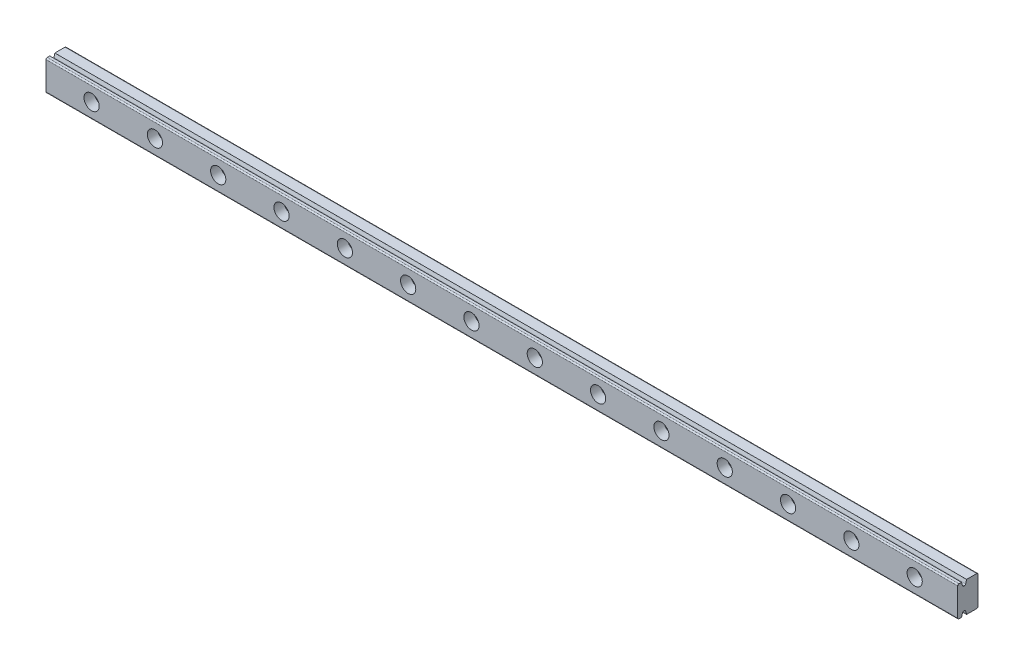
from build123d import *

# Parameters (mm, degrees)
BOSS_EXTRUDE1_DEPTH     = 450
SKETCH2_R               = 1.75
CUT_EXTRUDE1_DEPTH      = 10
SKETCH3_R               = 3
CUT_EXTRUDE2_DEPTH      = 4
CHAMFER1_SIZE           = 0.5
CHAMFER1_SIZE2          = 1.743707222
CHAMFER1_PART_2_SIZE    = 0.5
CHAMFER1_PART_2_SIZE2   = 1.743707222
FILLET1_R               = 0.5
SKETCH4_W               = 45
SKETCH4_H               = 180.260452365
SKETCH4_H_2             = 288.291106743
CUT_EXTRUDE3_DEPTH      = 1
CUT_EXTRUDE3_DEPTH_BACK = 9


with BuildPart() as part:
    # Sketch1 → Boss-Extrude1 (new body)
    with BuildSketch(Plane(origin=(0, 0, 0), x_dir=(0, 0, -1), z_dir=(1, 0, 0))):
        Polygon((-0.5, 6), (4, 6), (4, -6), (-0.5, -6), (-0.5, -4.25), (-2.5, -4.25), (-2.5, -6), (-4, -6), (-4, 6), (-2.5, 6), (-2.5, 4.25), (-0.5, 4.25), align=None)
    extrude(amount=BOSS_EXTRUDE1_DEPTH)

    # Sketch2 → Cut-Extrude1 (cut)
    with BuildSketch(Plane.XY.offset(4)):
        with Locations((13, 0)):
            Circle(SKETCH2_R)
        with Locations((38, 0)):
            Circle(SKETCH2_R)
        with Locations((63, 0)):
            Circle(SKETCH2_R)
        with Locations((88, 0)):
            Circle(SKETCH2_R)
        with Locations((113, 0)):
            Circle(SKETCH2_R)
        with Locations((138, 0)):
            Circle(SKETCH2_R)
        with Locations((163, 0)):
            Circle(SKETCH2_R)
        with Locations((188, 0)):
            Circle(SKETCH2_R)
        with Locations((213, 0)):
            Circle(SKETCH2_R)
        with Locations((238, 0)):
            Circle(SKETCH2_R)
        with Locations((263, 0)):
            Circle(SKETCH2_R)
        with Locations((288, 0)):
            Circle(SKETCH2_R)
        with Locations((313, 0)):
            Circle(SKETCH2_R)
        with Locations((338, 0)):
            Circle(SKETCH2_R)
        with Locations((363, 0)):
            Circle(SKETCH2_R)
        with Locations((388, 0)):
            Circle(SKETCH2_R)
        with Locations((413, 0)):
            Circle(SKETCH2_R)
        with Locations((438, 0)):
            Circle(SKETCH2_R)
    extrude(amount=-CUT_EXTRUDE1_DEPTH, mode=Mode.SUBTRACT)

    # Sketch3 → Cut-Extrude2 (cut)
    with BuildSketch(Plane.XY.offset(4)):
        with Locations((13, 0)):
            Circle(SKETCH3_R)
        with Locations((38, 0)):
            Circle(SKETCH3_R)
        with Locations((63, 0)):
            Circle(SKETCH3_R)
        with Locations((88, 0)):
            Circle(SKETCH3_R)
        with Locations((113, 0)):
            Circle(SKETCH3_R)
        with Locations((138, 0)):
            Circle(SKETCH3_R)
        with Locations((163, 0)):
            Circle(SKETCH3_R)
        with Locations((188, 0)):
            Circle(SKETCH3_R)
        with Locations((213, 0)):
            Circle(SKETCH3_R)
        with Locations((238, 0)):
            Circle(SKETCH3_R)
        with Locations((263, 0)):
            Circle(SKETCH3_R)
        with Locations((288, 0)):
            Circle(SKETCH3_R)
        with Locations((313, 0)):
            Circle(SKETCH3_R)
        with Locations((338, 0)):
            Circle(SKETCH3_R)
        with Locations((363, 0)):
            Circle(SKETCH3_R)
        with Locations((388, 0)):
            Circle(SKETCH3_R)
        with Locations((413, 0)):
            Circle(SKETCH3_R)
        with Locations((438, 0)):
            Circle(SKETCH3_R)
    extrude(amount=-CUT_EXTRUDE2_DEPTH, mode=Mode.SUBTRACT)

    # Chamfer1
    chamfer1_edges = [part.edges().sort_by_distance(p)[0] for p in [
        (225, -4.25, 0.5),
        (225, -4.25, 2.5),
    ]]
    chamfer1_side = [part.faces().sort_by_distance(p)[0] for p in [
        (225, -4.25, 1.5),
    ]]
    chamfer(chamfer1_edges, length=CHAMFER1_SIZE, length2=CHAMFER1_SIZE2, reference=chamfer1_side[0])

    # Chamfer1 part 2
    chamfer1_part_2_edges = [part.edges().sort_by_distance(p)[0] for p in [
        (225, 4.25, 2.5),
        (225, 4.25, 0.5),
    ]]
    chamfer1_part_2_side = [part.faces().sort_by_distance(p)[0] for p in [
        (225, 4.25, 1.5),
    ]]
    chamfer(chamfer1_part_2_edges, length=CHAMFER1_PART_2_SIZE, length2=CHAMFER1_PART_2_SIZE2, reference=chamfer1_part_2_side[0])

    # Fillet1
    fillet1_edges = [part.edges().sort_by_distance(p)[0] for p in [
        (450, -6, -1.75),
        (450, 0, -4),
        (450, 6, -1.75),
        (450, 6, 3.25),
        (450, 0, 4),
        (450, -6, 3.25),
        (0, -6, 3.25),
        (0, -6, -1.75),
        (0, 0, -4),
        (0, 6, -1.75),
        (0, 6, 3.25),
        (0, 0, 4),
        (225, -4.25, 1),
        (225, -4.25, 2),
        (225, 4.25, 2),
        (225, 4.25, 1),
        (225, -6, 4),
        (225, 6, 4),
        (225, -6, -4),
        (225, 6, -4),
    ]]
    fillet(fillet1_edges, radius=FILLET1_R)

    # Sketch4 → Cut-Extrude3 (cut, two sides)
    with BuildSketch(Plane.XY.offset(4)) as cut_extrude3_sk:
        with Locations((22.5, -21.668939395)):
            Rectangle(SKETCH4_W, SKETCH4_H)
        with Locations((427.5, 22.925109796)):
            Rectangle(SKETCH4_W, SKETCH4_H_2)
    extrude(amount=CUT_EXTRUDE3_DEPTH, mode=Mode.SUBTRACT)
    extrude(cut_extrude3_sk.sketch, amount=-CUT_EXTRUDE3_DEPTH_BACK, mode=Mode.SUBTRACT)


solid = part.part
